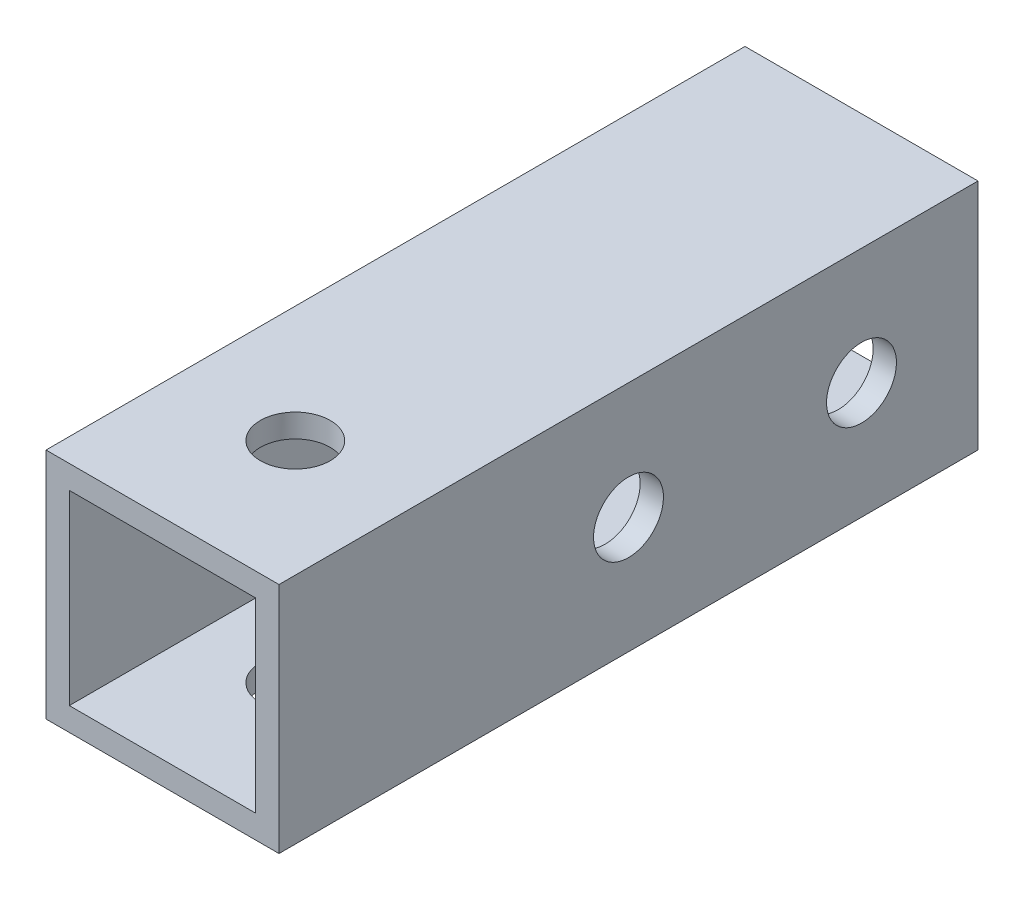
from build123d import *

# Parameters (mm, degrees)
SKETCH_1_W          = 10
SKETCH_1_H          = 10
SKETCH_1_W_2        = 8
SKETCH_1_H_2        = 8
EXTRUDE_1_DEPTH     = 30
SKETCH_2_R          = 1.5
CUT_EXTRUDE_1_DEPTH = 11
SKETCH_3_R          = 1.5
CUT_EXTRUDE_2_DEPTH = 11


with BuildPart() as part:
    # 草图1 → 拉伸-薄壁1 (new body)
    with BuildSketch(Plane.XY):
        Rectangle(SKETCH_1_W, SKETCH_1_H)
        Rectangle(SKETCH_1_W_2, SKETCH_1_H_2, mode=Mode.SUBTRACT)
    extrude(amount=EXTRUDE_1_DEPTH)

    # 草图2 → 切除-拉伸1 (cut, through all)
    with BuildSketch(Plane(origin=(5, 0, 0), x_dir=(0, 0, -1), z_dir=(1, 0, 0))):
        with Locations((-5, 0)):
            Circle(SKETCH_2_R)
        with Locations((-15, 0)):
            Circle(SKETCH_2_R)
    extrude(amount=-CUT_EXTRUDE_1_DEPTH, mode=Mode.SUBTRACT)

    # 草图3 → 切除-拉伸2 (cut, through all)
    with BuildSketch(Plane(origin=(0, 5, 0), x_dir=(1, 0, 0), z_dir=(0, 1, 0))):
        with Locations((0, -24.3)):
            Circle(SKETCH_3_R)
    extrude(amount=-CUT_EXTRUDE_2_DEPTH, mode=Mode.SUBTRACT)


solid = part.part
